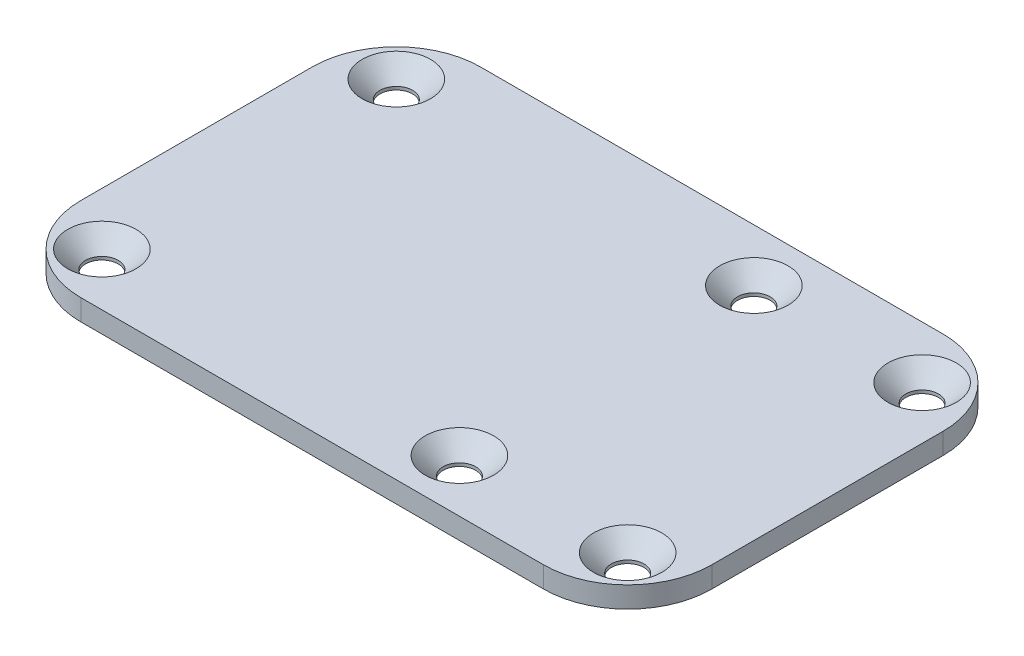
from build123d import *

# Parameters (mm, degrees)
BASE_DEPTH                          = 2
F_3_1_3_1_DIAMETER_HOLE1_AT_2_COUNT = 2
F_3_1_3_1_DIAMETER_HOLE1_AT_2_PITCH = 28
F_3_1_3_1_DIAMETER_HOLE1_AT_3_COUNT = 2
F_3_1_3_1_DIAMETER_HOLE1_AT_3_PITCH = 57.306195128
F_3_1_3_1_DIAMETER_HOLE1_AT_4_COUNT = 2
F_3_1_3_1_DIAMETER_HOLE1_AT_4_PITCH = 50
F_3_1_3_1_DIAMETER_HOLE1_AT_5_COUNT = 2
F_3_1_3_1_DIAMETER_HOLE1_AT_5_PITCH = 16
F_3_1_3_1_DIAMETER_HOLE1_AT_6_COUNT = 2
F_3_1_3_1_DIAMETER_HOLE1_AT_6_PITCH = 32.249030993


with BuildPart() as part:
    # Sketch1 → Base (new body)
    with BuildSketch(Plane(origin=(0, 0, 0), x_dir=(1, 0, 0), z_dir=(0, 1, 0))):
        with BuildLine():
            Line((22, -19), (-22, -19))
            ThreePointArc((-22, -19), (-27.656854249, -16.656854249), (-30, -11))
            Line((-30, -11), (-30, 11))
            ThreePointArc((-30, 11), (-27.656854249, 16.656854249), (-22, 19))
            Line((-22, 19), (22, 19))
            ThreePointArc((22, 19), (27.656854249, 16.656854249), (30, 11))
            Line((30, 11), (30, -11))
            ThreePointArc((30, -11), (27.656854249, -16.656854249), (22, -19))
        make_face()
    extrude(amount=BASE_DEPTH)

    # Hole → Ø3.1 (3.1) Diameter Hole1 (revolve, cut)
    with BuildSketch(Plane(origin=(25, 2, -14), x_dir=(0, 0, 1), z_dir=(1, 0, 0))):
        Polygon((0, 0), (0, 2), (1.55, 2), (1.55, 1.7), (3.25, 0), align=None)
    f_3_1_3_1_diameter_hole1 = revolve(axis=Axis((25, 8.35, -14), (0, -1, 0)), mode=Mode.SUBTRACT)

    # Ø3.1 (3.1) Diameter Hole1 at 2: Ø3.1 (3.1) Diameter Hole1 ×2
    with Locations(*[(0, 0, i * F_3_1_3_1_DIAMETER_HOLE1_AT_2_PITCH) for i in range(1, F_3_1_3_1_DIAMETER_HOLE1_AT_2_COUNT)]):
        add(f_3_1_3_1_diameter_hole1, mode=Mode.SUBTRACT)

    # Ø3.1 (3.1) Diameter Hole1 at 3: Ø3.1 (3.1) Diameter Hole1 ×2
    with Locations(*[Vector(-0.872506016, 0, 0.488603369) * (i * F_3_1_3_1_DIAMETER_HOLE1_AT_3_PITCH) for i in range(1, F_3_1_3_1_DIAMETER_HOLE1_AT_3_COUNT)]):
        add(f_3_1_3_1_diameter_hole1, mode=Mode.SUBTRACT)

    # Ø3.1 (3.1) Diameter Hole1 at 4: Ø3.1 (3.1) Diameter Hole1 ×2
    with Locations(*[(-i * F_3_1_3_1_DIAMETER_HOLE1_AT_4_PITCH, 0, 0) for i in range(1, F_3_1_3_1_DIAMETER_HOLE1_AT_4_COUNT)]):
        add(f_3_1_3_1_diameter_hole1, mode=Mode.SUBTRACT)

    # Ø3.1 (3.1) Diameter Hole1 at 5: Ø3.1 (3.1) Diameter Hole1 ×2
    with Locations(*[(-i * F_3_1_3_1_DIAMETER_HOLE1_AT_5_PITCH, 0, 0) for i in range(1, F_3_1_3_1_DIAMETER_HOLE1_AT_5_COUNT)]):
        add(f_3_1_3_1_diameter_hole1, mode=Mode.SUBTRACT)

    # Ø3.1 (3.1) Diameter Hole1 at 6: Ø3.1 (3.1) Diameter Hole1 ×2
    with Locations(*[Vector(-0.496138938, 0, 0.868243142) * (i * F_3_1_3_1_DIAMETER_HOLE1_AT_6_PITCH) for i in range(1, F_3_1_3_1_DIAMETER_HOLE1_AT_6_COUNT)]):
        add(f_3_1_3_1_diameter_hole1, mode=Mode.SUBTRACT)


solid = part.part
